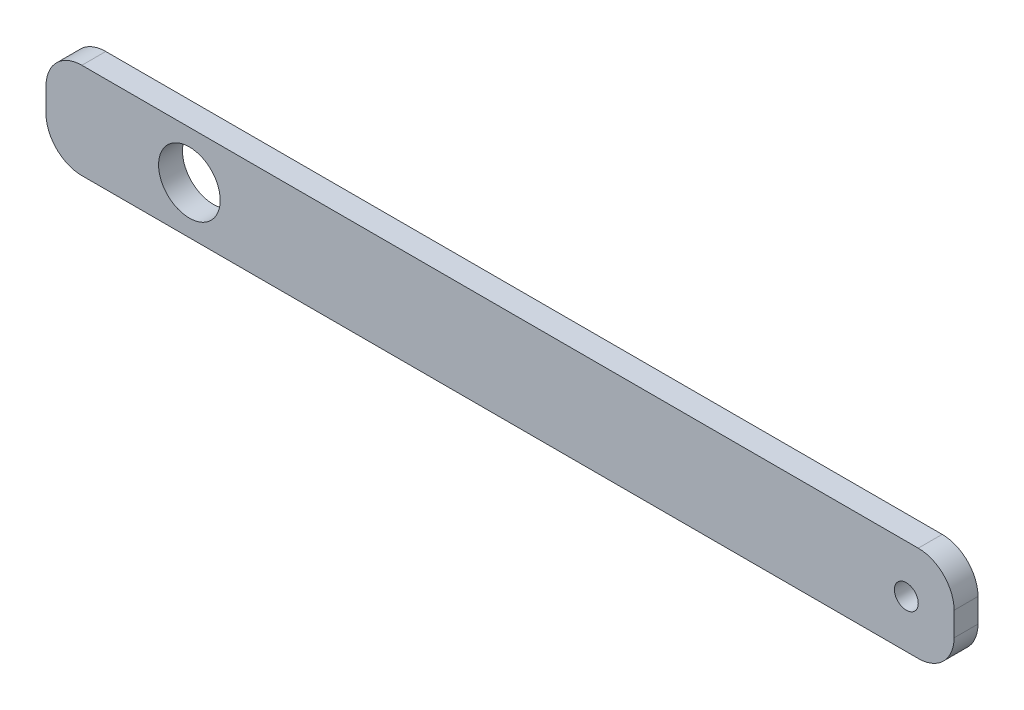
from build123d import *

# Parameters (mm, degrees)
SKETCH1_W           = 190
SKETCH1_H           = 20
SKETCH1_R           = 6.45
SKETCH1_R_2         = 2.5
BOSS_EXTRUDE1_DEPTH = 5
FILLET1_R           = 7.5


with BuildPart() as part:
    # Sketch1 → Boss-Extrude1 (new body)
    with BuildSketch(Plane.XY):
        Rectangle(SKETCH1_W, SKETCH1_H)
        with Locations((-65, 0)):
            Circle(SKETCH1_R, mode=Mode.SUBTRACT)
        with Locations((85, 0)):
            Circle(SKETCH1_R_2, mode=Mode.SUBTRACT)
    extrude(amount=BOSS_EXTRUDE1_DEPTH)

    # Fillet1
    fillet1_edges = [part.edges().sort_by_distance(p)[0] for p in [
        (-95, 10, 2.5),
        (95, 10, 2.5),
        (95, -10, 2.5),
        (-95, -10, 2.5),
    ]]
    fillet(fillet1_edges, radius=FILLET1_R)


solid = part.part
